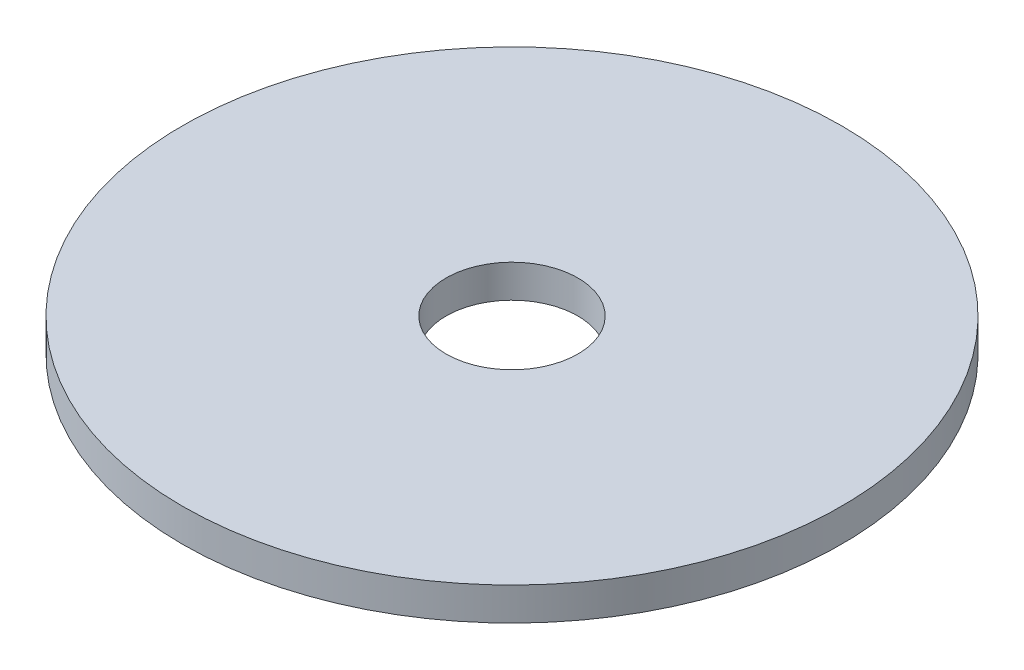
from build123d import *

# Parameters (mm, degrees)
SKETCH1_R           = 63.5
SKETCH1_R_2         = 12.7
BOSS_EXTRUDE1_DEPTH = 6.35


with BuildPart() as part:
    # Sketch1 → Boss-Extrude1 (new body)
    with BuildSketch(Plane(origin=(0, 0, 0), x_dir=(1, 0, 0), z_dir=(0, 1, 0))):
        Circle(SKETCH1_R)
        Circle(SKETCH1_R_2, mode=Mode.SUBTRACT)
    extrude(amount=BOSS_EXTRUDE1_DEPTH)


solid = part.part
